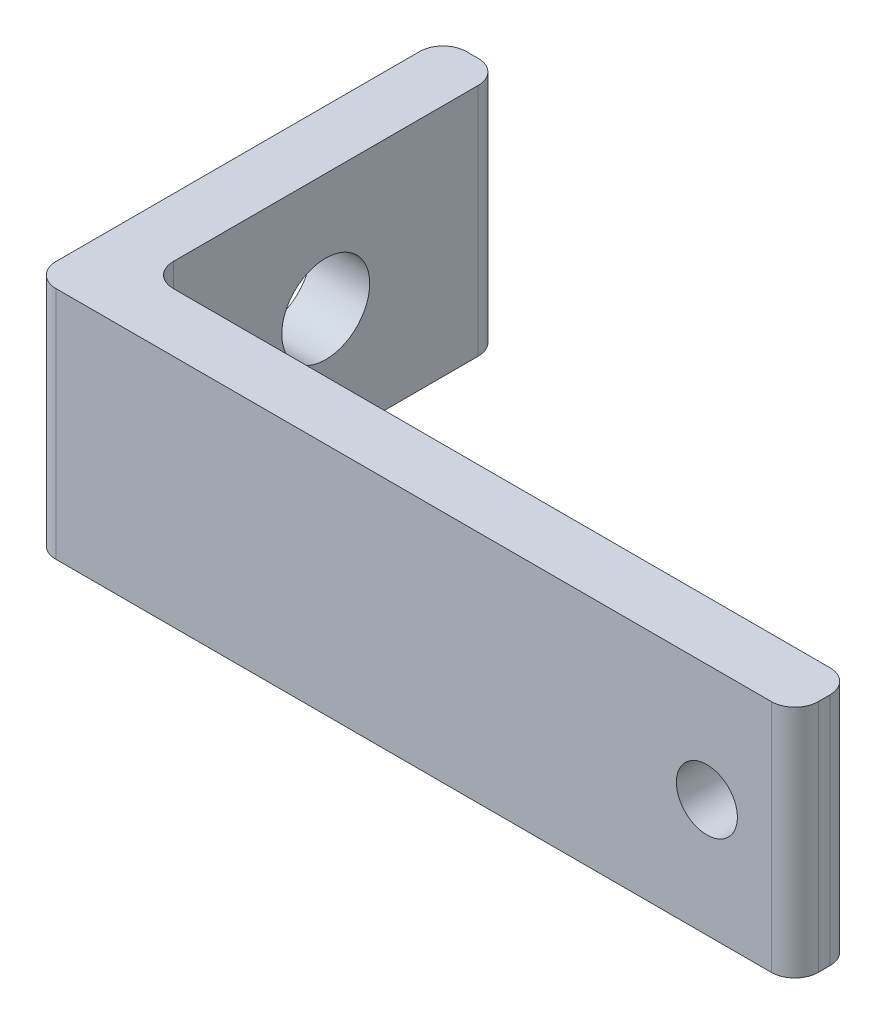
from build123d import *

# Parameters (mm, degrees)
SKETCH1_W           = 6.35
SKETCH1_H           = 38.1
SKETCH1_H_2         = 6.35
SKETCH1_W_2         = 76.2
BOSS_EXTRUDE1_DEPTH = 25.4
SKETCH2_R           = 3.302
CUT_EXTRUDE1_DEPTH  = 7.35
SKETCH3_R           = 4.7625
CUT_EXTRUDE2_DEPTH  = 7.35
FILLET1_R           = 2.54


with BuildPart() as part:
    # Sketch1 → Boss-Extrude1 (new body)
    with BuildSketch(Plane(origin=(0, 0, 0), x_dir=(1, 0, 0), z_dir=(0, 1, 0))):
        with Locations((3.175, 25.4)):
            Rectangle(SKETCH1_W, SKETCH1_H)
        with Locations((3.175, 3.175)):
            Rectangle(SKETCH1_W, SKETCH1_H_2)
        with Locations((44.45, 3.175)):
            Rectangle(SKETCH1_W_2, SKETCH1_H_2)
    extrude(amount=BOSS_EXTRUDE1_DEPTH)

    # Sketch2 → Cut-Extrude1 (cut, through all)
    with BuildSketch(Plane(origin=(0, 0, -6.35), x_dir=(-1, 0, 0), z_dir=(0, 0, -1))):
        with Locations((-73.025, 12.7)):
            Circle(SKETCH2_R)
    extrude(amount=-CUT_EXTRUDE1_DEPTH, mode=Mode.SUBTRACT)

    # Sketch3 → Cut-Extrude2 (cut, through all)
    with BuildSketch(Plane(origin=(6.35, 0, 0), x_dir=(0, 0, -1), z_dir=(1, 0, 0))):
        with Locations((25.4, 12.7)):
            Circle(SKETCH3_R)
    extrude(amount=-CUT_EXTRUDE2_DEPTH, mode=Mode.SUBTRACT)

    # Fillet1
    fillet1_edges = [part.edges().sort_by_distance(p)[0] for p in [
        (0, 12.7, -44.45),
        (6.35, 12.7, -44.45),
        (6.35, 12.7, -6.35),
        (82.55, 12.7, -6.35),
        (82.55, 12.7, 0),
        (0, 12.7, 0),
    ]]
    fillet(fillet1_edges, radius=FILLET1_R)


solid = part.part
